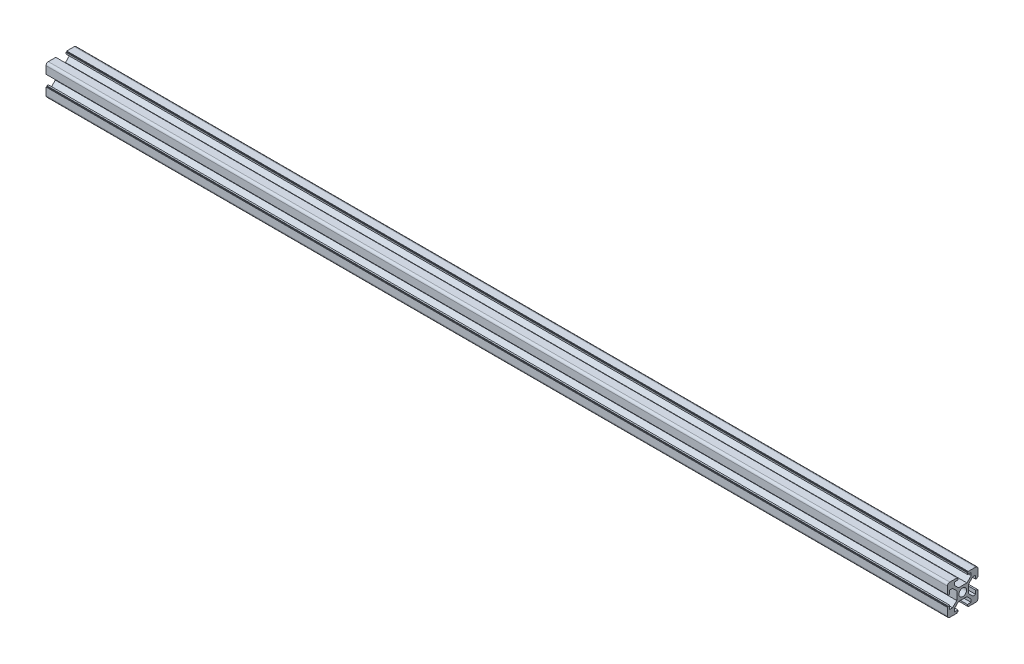
from build123d import *

# Parameters (mm, degrees)
SKETCH1_R                = 2.5
F_20_X_20_X_R1_5_1_DEPTH = 590


with BuildPart() as part:
    # Sketch1 → 铝型材 20 X 20 X R1.5(1) (new body)
    with BuildSketch(Plane(origin=(0, 0, 0), x_dir=(0, 0, -1), z_dir=(1, 0, 0))):
        with BuildLine():
            Line((-3.6, 10), (-3.6, 9.5))
            Line((-3.6, 9.5), (-3.1, 9.5))
            Line((-3.1, 9.5), (-3.1, 8.5))
            Line((-3.1, 8.5), (-5.5, 8.5))
            Line((-5.5, 8.5), (-5.5, 6.65))
            Line((-5.5, 6.65), (-2.75, 3.9))
            Line((-2.75, 3.9), (2.75, 3.9))
            Line((2.75, 3.9), (5.5, 6.65))
            Line((5.5, 6.65), (5.5, 8.5))
            Line((5.5, 8.5), (3.1, 8.5))
            Line((3.1, 8.5), (3.1, 9.5))
            Line((3.1, 9.5), (3.6, 9.5))
            Line((3.6, 9.5), (3.6, 10))
            Line((3.6, 10), (8.5, 10))
            ThreePointArc((8.5, 10), (9.560660172, 9.560660172), (10, 8.5))
            Line((10, 8.5), (10, 3.6))
            Line((10, 3.6), (9.5, 3.6))
            Line((9.5, 3.6), (9.5, 3.1))
            Line((9.5, 3.1), (8.5, 3.1))
            Line((8.5, 3.1), (8.5, 5.5))
            Line((8.5, 5.5), (6.65, 5.5))
            Line((6.65, 5.5), (3.9, 2.75))
            Line((3.9, 2.75), (3.9, -2.75))
            Line((3.9, -2.75), (6.65, -5.5))
            Line((6.65, -5.5), (8.5, -5.5))
            Line((8.5, -5.5), (8.5, -3.1))
            Line((8.5, -3.1), (9.5, -3.1))
            Line((9.5, -3.1), (9.5, -3.6))
            Line((9.5, -3.6), (10, -3.6))
            Line((10, -3.6), (10, -8.5))
            ThreePointArc((10, -8.5), (9.560660172, -9.560660172), (8.5, -10))
            Line((8.5, -10), (3.6, -10))
            Line((3.6, -10), (3.6, -9.5))
            Line((3.6, -9.5), (3.1, -9.5))
            Line((3.1, -9.5), (3.1, -8.5))
            Line((3.1, -8.5), (5.5, -8.5))
            Line((5.5, -8.5), (5.5, -6.65))
            Line((5.5, -6.65), (2.75, -3.9))
            Line((2.75, -3.9), (-2.75, -3.9))
            Line((-2.75, -3.9), (-5.5, -6.65))
            Line((-5.5, -6.65), (-5.5, -8.5))
            Line((-5.5, -8.5), (-3.1, -8.5))
            Line((-3.1, -8.5), (-3.1, -9.5))
            Line((-3.1, -9.5), (-3.6, -9.5))
            Line((-3.6, -9.5), (-3.6, -10))
            Line((-3.6, -10), (-8.5, -10))
            ThreePointArc((-8.5, -10), (-9.560660172, -9.560660172), (-10, -8.5))
            Line((-10, -8.5), (-10, -3.6))
            Line((-10, -3.6), (-9.5, -3.6))
            Line((-9.5, -3.6), (-9.5, -3.1))
            Line((-9.5, -3.1), (-8.5, -3.1))
            Line((-8.5, -3.1), (-8.5, -5.5))
            Line((-8.5, -5.5), (-6.65, -5.5))
            Line((-6.65, -5.5), (-3.9, -2.75))
            Line((-3.9, -2.75), (-3.9, 2.75))
            Line((-3.9, 2.75), (-6.65, 5.5))
            Line((-6.65, 5.5), (-8.5, 5.5))
            Line((-8.5, 5.5), (-8.5, 3.1))
            Line((-8.5, 3.1), (-9.5, 3.1))
            Line((-9.5, 3.1), (-9.5, 3.6))
            Line((-9.5, 3.6), (-10, 3.6))
            Line((-10, 3.6), (-10, 8.5))
            ThreePointArc((-10, 8.5), (-9.560660172, 9.560660172), (-8.5, 10))
            Line((-8.5, 10), (-3.6, 10))
        make_face()
        Circle(SKETCH1_R, mode=Mode.SUBTRACT)
    extrude(amount=F_20_X_20_X_R1_5_1_DEPTH)


solid = part.part
